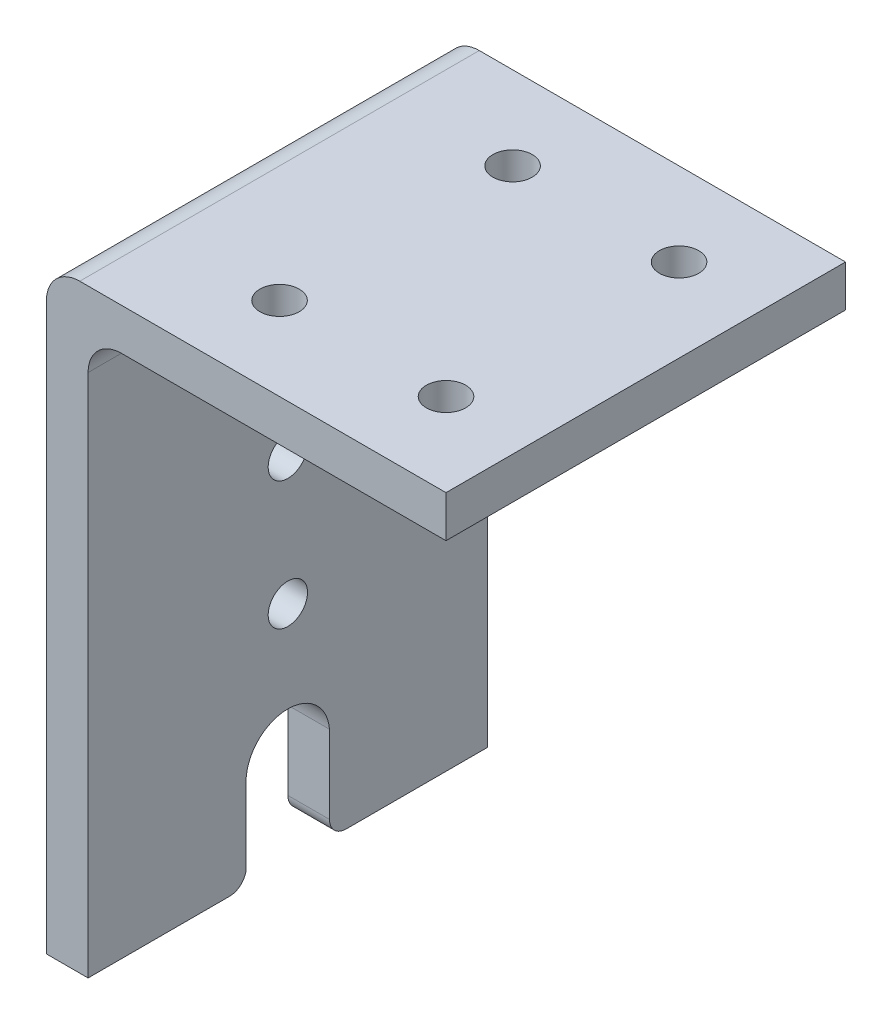
from build123d import *

# Parameters (mm, degrees)
BOSS_EXTRUDE1_DEPTH          = 30.48
FILLET1_R                    = 2.54
F_3_0_3_DIAMETER_HOLE2_D     = 3
F_3_0_3_DIAMETER_HOLE2_DEPTH = 3.175
F_3_0_3_DIAMETER_HOLE1_D     = 3
F_3_0_3_DIAMETER_HOLE1_DEPTH = 3.175
CUT_EXTRUDE1_DEPTH           = 3.175
FILLET2_R                    = 1.27


with BuildPart() as part:
    # Sketch1 → Boss-Extrude1 (new body)
    with BuildSketch(Plane.XY):
        Polygon((-1.5875, 3.175), (-1.5875, -42.545), (1.5875, -42.545), (1.5875, 0), (28.8925, 0), (28.8925, 3.175), align=None)
    extrude(amount=BOSS_EXTRUDE1_DEPTH)

    # Fillet1
    fillet1_edges = [part.edges().sort_by_distance(p)[0] for p in [
        (1.5875, 0, 15.24),
        (-1.5875, 3.175, 15.24),
    ]]
    fillet(fillet1_edges, radius=FILLET1_R)

    # Ø3.0 (3) Diameter Hole2
    with Locations(Plane(origin=(1.5875, 0, 0), x_dir=(0, 0, -1), z_dir=(1, 0, 0))):
        with Locations((-15.24, -15.6591), (-15.24, -25.4381)):
            Hole(F_3_0_3_DIAMETER_HOLE2_D / 2, depth=F_3_0_3_DIAMETER_HOLE2_DEPTH)

    # Ø3.0 (3) Diameter Hole1
    with Locations(Plane(origin=(0, 0, 0), x_dir=(-1, 0, 0), z_dir=(0, -1, 0))):
        with Locations((-22.5425, -6.35), (-9.8425, -6.35), (-9.8425, -24.13), (-22.5425, -24.13)):
            Hole(F_3_0_3_DIAMETER_HOLE1_D / 2, depth=F_3_0_3_DIAMETER_HOLE1_DEPTH)

    # Sketch7 → Cut-Extrude1 (cut)
    with BuildSketch(Plane(origin=(1.5875, 0, 0), x_dir=(0, 0, -1), z_dir=(1, 0, 0))):
        with BuildLine():
            Line((-18.415, -42.545), (-18.415, -35.317518126))
            ThreePointArc((-18.415, -35.317518126), (-15.24, -32.385), (-12.065, -35.317518126))
            Line((-12.065, -35.317518126), (-12.065, -42.545))
            Line((-12.065, -42.545), (-18.415, -42.545))
        make_face()
    extrude(amount=-CUT_EXTRUDE1_DEPTH, mode=Mode.SUBTRACT)

    # Fillet2
    fillet2_edges = [part.edges().sort_by_distance(p)[0] for p in [
        (0, -42.545, 12.065),
        (0, -42.545, 18.415),
    ]]
    fillet(fillet2_edges, radius=FILLET2_R)


solid = part.part
